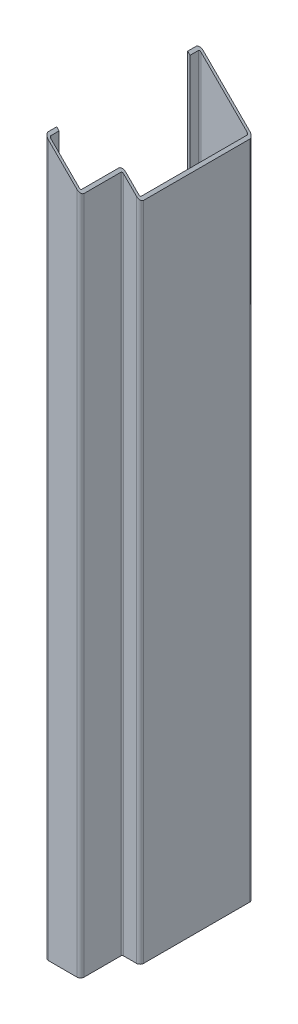
from build123d import *

# Parameters (mm, degrees)
VYSUNOUT_TENKOST_NN_1_DEPTH = 600
ODEBRAT_VYSUNUT_M1_DEPTH    = 130


with BuildPart() as part:
    # Skica1 → Vysunout tenkostěnný1 (new body)
    with BuildSketch(Plane(origin=(0, 0, 0), x_dir=(1, 0, 0), z_dir=(0, 1, 0))):
        with BuildLine():
            Line((-22.5, -55), (-22.5, -62))
            ThreePointArc((-22.5, -62), (-21.621320344, -64.121320344), (-19.5, -65))
            Line((-19.5, -65), (4.5, -65))
            ThreePointArc((4.5, -65), (6.621320344, -64.121320344), (7.5, -62))
            Line((7.5, -62), (7.5, -31))
            ThreePointArc((7.5, -31), (7.792893219, -30.292893219), (8.5, -30))
            Line((8.5, -30), (19.5, -30))
            ThreePointArc((19.5, -30), (21.621320344, -29.121320344), (22.5, -27))
            Line((22.5, -27), (22.5, 62))
            ThreePointArc((22.5, 62), (21.621320344, 64.121320344), (19.5, 65))
            Line((19.5, 65), (-19.5, 65))
            ThreePointArc((-19.5, 65), (-21.621320344, 64.121320344), (-22.5, 62))
            Line((-22.5, 62), (-22.5, 55))
            Line((-22.5, 55), (-20.5, 55))
            Line((-20.5, 55), (-20.5, 62))
            ThreePointArc((-20.5, 62), (-20.207106781, 62.707106781), (-19.5, 63))
            Line((-19.5, 63), (19.5, 63))
            ThreePointArc((19.5, 63), (20.207106781, 62.707106781), (20.5, 62))
            Line((20.5, 62), (20.5, -27))
            ThreePointArc((20.5, -27), (20.207106781, -27.707106781), (19.5, -28))
            Line((19.5, -28), (8.5, -28))
            ThreePointArc((8.5, -28), (6.378679656, -28.878679656), (5.5, -31))
            Line((5.5, -31), (5.5, -62))
            ThreePointArc((5.5, -62), (5.207106781, -62.707106781), (4.5, -63))
            Line((4.5, -63), (-19.5, -63))
            ThreePointArc((-19.5, -63), (-20.207106781, -62.707106781), (-20.5, -62))
            Line((-20.5, -62), (-20.5, -55))
            Line((-20.5, -55), (-22.5, -55))
        make_face()
    extrude(amount=VYSUNOUT_TENKOST_NN_1_DEPTH)

    # Skica2 → Odebrat vysunutím1 (cut)
    with BuildSketch(Plane.XY.offset(65)):
        Polygon((-22.5, 600), (22.5, 555), (22.5, 600), align=None)
    extrude(amount=-ODEBRAT_VYSUNUT_M1_DEPTH, mode=Mode.SUBTRACT)


solid = part.part
